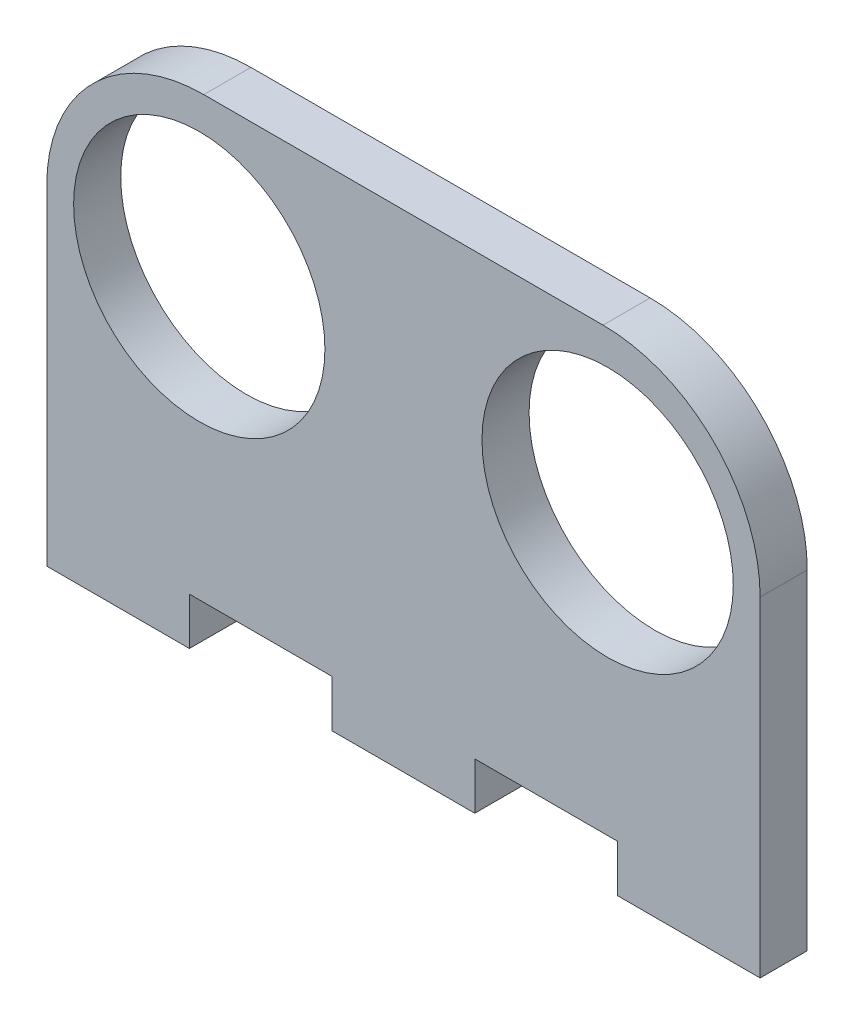
from build123d import *

# Parameters (mm, degrees)
SALIENTE_EXTRUIR1_DEPTH = 3
CROQUIS3_R              = 8
CORTAR_EXTRUIR2_DEPTH   = 3
CROQUIS5_W              = 9.084
CROQUIS5_H              = 3
SALIENTE_EXTRUIR2_DEPTH = 3


with BuildPart() as part:
    # Croquis1 → Saliente-Extruir1 (new body)
    with BuildSketch(Plane.XY):
        with BuildLine():
            Line((-22.71, -10.17), (22.71, -10.17))
            Line((22.71, -10.17), (22.71, 7.83))
            ThreePointArc((22.71, 7.83), (19.781067812, 14.901067812), (12.71, 17.83))
            Line((12.71, 17.83), (-12.71, 17.83))
            ThreePointArc((-12.71, 17.83), (-19.781067812, 14.901067812), (-22.71, 7.83))
            Line((-22.71, 7.83), (-22.71, -10.17))
        make_face()
    extrude(amount=SALIENTE_EXTRUIR1_DEPTH)

    # Croquis3 → Cortar-Extruir2 (cut)
    with BuildSketch(Plane.XY.offset(3)):
        with Locations((-13, 7.65)):
            Circle(CROQUIS3_R)
        with Locations((13, 7.65)):
            Circle(CROQUIS3_R)
    extrude(amount=-CORTAR_EXTRUIR2_DEPTH, mode=Mode.SUBTRACT)

    # Croquis5 → Saliente-Extruir2 (add)
    with BuildSketch(Plane.XZ.offset(10.17)):
        with Locations((-18.168, 1.5)):
            Rectangle(CROQUIS5_W, CROQUIS5_H)
        with Locations((0, 1.5)):
            Rectangle(CROQUIS5_W, CROQUIS5_H)
        with Locations((18.168, 1.5)):
            Rectangle(CROQUIS5_W, CROQUIS5_H)
    extrude(amount=SALIENTE_EXTRUIR2_DEPTH)


solid = part.part
